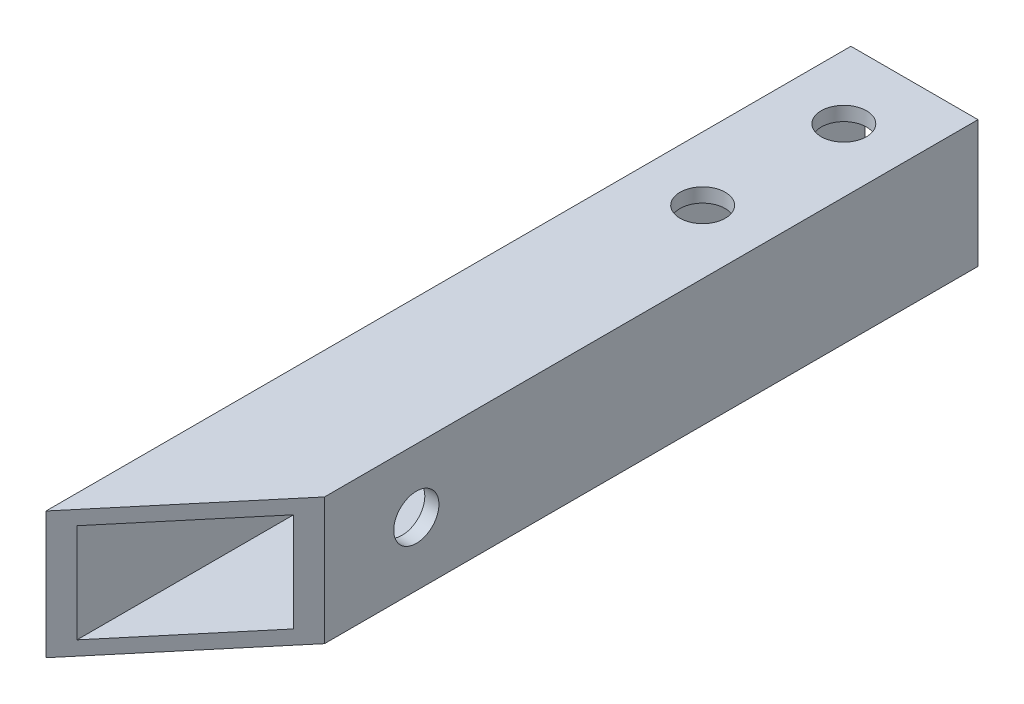
from build123d import *

# Parameters (mm, degrees)
SKETCH_1_W          = 9
SKETCH_1_H          = 9
SKETCH_1_W_2        = 7
SKETCH_1_H_2        = 7
EXTRUDE_1_DEPTH     = 70
SKETCH_2_R          = 1.6
CUT_EXTRUDE_1_DEPTH = 50
CUT_EXTRUDE_2_DEPTH = 10
SKETCH_4_W          = 9
SKETCH_4_H          = 13
CUT_EXTRUDE_3_DEPTH = 10
SKETCH_5_R          = 1.6
CUT_EXTRUDE_4_DEPTH = 400


with BuildPart() as part:
    # ｽｹｯﾁ1 → ﾎﾞｽ - 押し出し1 (new body)
    with BuildSketch(Plane.XY):
        Rectangle(SKETCH_1_W, SKETCH_1_H)
        Rectangle(SKETCH_1_W_2, SKETCH_1_H_2, mode=Mode.SUBTRACT)
    extrude(amount=EXTRUDE_1_DEPTH)

    # ｽｹｯﾁ2 → ｶｯﾄ - 押し出し1 (cut)
    with BuildSketch(Plane(origin=(0, 4.5, 0), x_dir=(1, 0, 0), z_dir=(0, 1, 0))):
        with Locations((0, -5)):
            Circle(SKETCH_2_R)
        with Locations((0, -15)):
            Circle(SKETCH_2_R)
    extrude(amount=-CUT_EXTRUDE_1_DEPTH, mode=Mode.SUBTRACT)

    # ｽｹｯﾁ3 → ｶｯﾄ - 押し出し2 (cut)
    with BuildSketch(Plane(origin=(0, 4.5, 0), x_dir=(1, 0, 0), z_dir=(0, 1, 0))):
        Polygon((4.5, -46.274217667), (-4.5, -57), (4.5, -57), align=None)
    extrude(amount=-CUT_EXTRUDE_2_DEPTH, mode=Mode.SUBTRACT)

    # ｽｹｯﾁ4 → ｶｯﾄ - 押し出し3 (cut)
    with BuildSketch(Plane(origin=(0, 4.5, 0), x_dir=(1, 0, 0), z_dir=(0, 1, 0))):
        with Locations((0, -63.5)):
            Rectangle(SKETCH_4_W, SKETCH_4_H)
    extrude(amount=-CUT_EXTRUDE_3_DEPTH, mode=Mode.SUBTRACT)

    # ｽｹｯﾁ5 → ｶｯﾄ - 押し出し4 (cut)
    with BuildSketch(Plane(origin=(4.5, 0, 0), x_dir=(0, 0, -1), z_dir=(1, 0, 0))):
        with Locations((-39.774217667, 0)):
            Circle(SKETCH_5_R)
    extrude(amount=-CUT_EXTRUDE_4_DEPTH, mode=Mode.SUBTRACT)


solid = part.part
